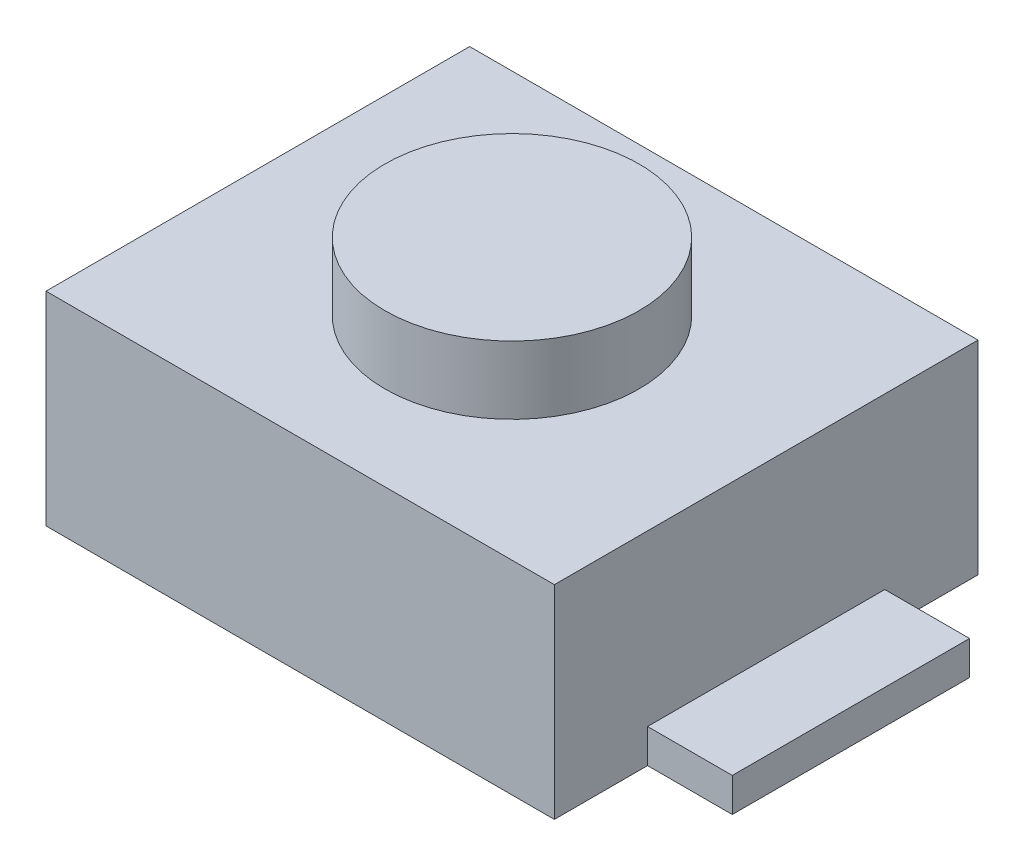
from build123d import *

# Parameters (mm, degrees)
SKETCH1_W           = 3
SKETCH1_H           = 2.5
BOSS_EXTRUDE1_DEPTH = 1.2
SKETCH2_W           = 1.4
SKETCH2_H           = 0.2
BOSS_EXTRUDE2_DEPTH = 0.5
SKETCH3_W           = 1.4
SKETCH3_H           = 0.2
BOSS_EXTRUDE3_DEPTH = 0.5
SKETCH4_W           = 0.75
SKETCH4_H           = 0.4


with BuildPart() as part:
    # Sketch1 → Boss-Extrude1 (new body)
    with BuildSketch(Plane.XZ):
        Rectangle(SKETCH1_W, SKETCH1_H)
    extrude(amount=-BOSS_EXTRUDE1_DEPTH)

    # Sketch2 → Boss-Extrude2 (add)
    with BuildSketch(Plane(origin=(1.5, 0, 0), x_dir=(0, 0, -1), z_dir=(1, 0, 0))):
        with Locations((0, 0.1)):
            Rectangle(SKETCH2_W, SKETCH2_H)
    extrude(amount=BOSS_EXTRUDE2_DEPTH)

    # Sketch3 → Boss-Extrude3 (add)
    with BuildSketch(Plane.ZY.offset(1.5)):
        with Locations((0, 0.1)):
            Rectangle(SKETCH3_W, SKETCH3_H)
    extrude(amount=BOSS_EXTRUDE3_DEPTH)

    # Sketch4 → Revolve1 (revolve)
    with BuildSketch(Plane(origin=(0, 0, 0), x_dir=(-1, 0, 0), z_dir=(0, 0, -1))):
        with Locations((-0.375, 1.4)):
            Rectangle(SKETCH4_W, SKETCH4_H)
    revolve(axis=Axis((0, 1.2, 0), (0, 1, 0)))


solid = part.part
